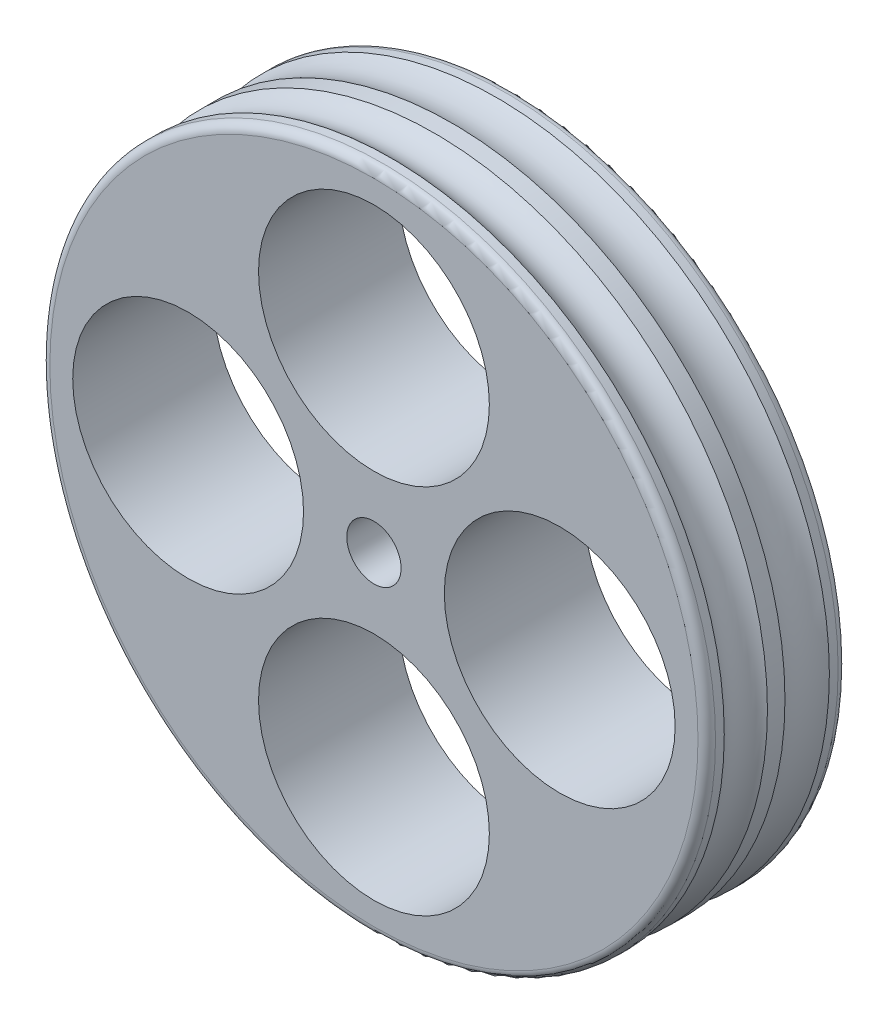
from build123d import *

# Parameters (mm, degrees)
SKETCH1_R           = 19
BOSS_EXTRUDE1_DEPTH = 8
FILLET1_R           = 0.5
SKETCH3_R           = 1.55
CUT_EXTRUDE1_DEPTH  = 8
SKETCH4_R           = 6.58897104
CUT_EXTRUDE2_DEPTH  = 8
CIRPATTERN1_COUNT   = 4


with BuildPart() as part:
    # Sketch1 → Boss-Extrude1 (new body)
    with BuildSketch(Plane.XY):
        Circle(SKETCH1_R)
    extrude(amount=BOSS_EXTRUDE1_DEPTH)

    # Sketch2 → Cut-Revolve1 (revolve, cut)
    with BuildSketch(Plane(origin=(0, 0, 0), x_dir=(0, 0, -1), z_dir=(1, 0, 0))):
        with BuildLine():
            Line((-7, 19), (-4.535200691, 19))
            ThreePointArc((-4.535200691, 19), (-5.767600345, 18.5), (-7, 19))
        make_face()
        with BuildLine():
            Line((-3.535200691, 19), (-1, 19))
            ThreePointArc((-1, 19), (-2.267600345, 18.7), (-3.535200691, 19))
        make_face()
    revolve(axis=Axis((0, 0, 8.4), (0, 0, -1)), mode=Mode.SUBTRACT)

    # Fillet1
    fillet1_edges = [part.edges().sort_by_distance(p)[0] for p in [
        (-19, 0, 0),
        (-19, 0, 8),
    ]]
    fillet(fillet1_edges, radius=FILLET1_R)

    # Sketch3 → Cut-Extrude1 (cut)
    with BuildSketch(Plane.XY.offset(8)):
        Circle(SKETCH3_R)
    extrude(amount=-CUT_EXTRUDE1_DEPTH, mode=Mode.SUBTRACT)

    # Sketch4 → Cut-Extrude2 (cut)
    with BuildSketch(Plane.XY.offset(8)):
        with Locations((0, 10.60646011)):
            Circle(SKETCH4_R)
    cut_extrude2 = extrude(amount=-CUT_EXTRUDE2_DEPTH, mode=Mode.SUBTRACT)

    # CirPattern1: Cut-Extrude2 ×4 about axis
    cirpattern1_axis = Axis((0, 0, 0), (0, 0, 1))
    for i in range(1, CIRPATTERN1_COUNT):
        add(cut_extrude2.rotate(cirpattern1_axis, i * 360 / CIRPATTERN1_COUNT), mode=Mode.SUBTRACT)


solid = part.part
